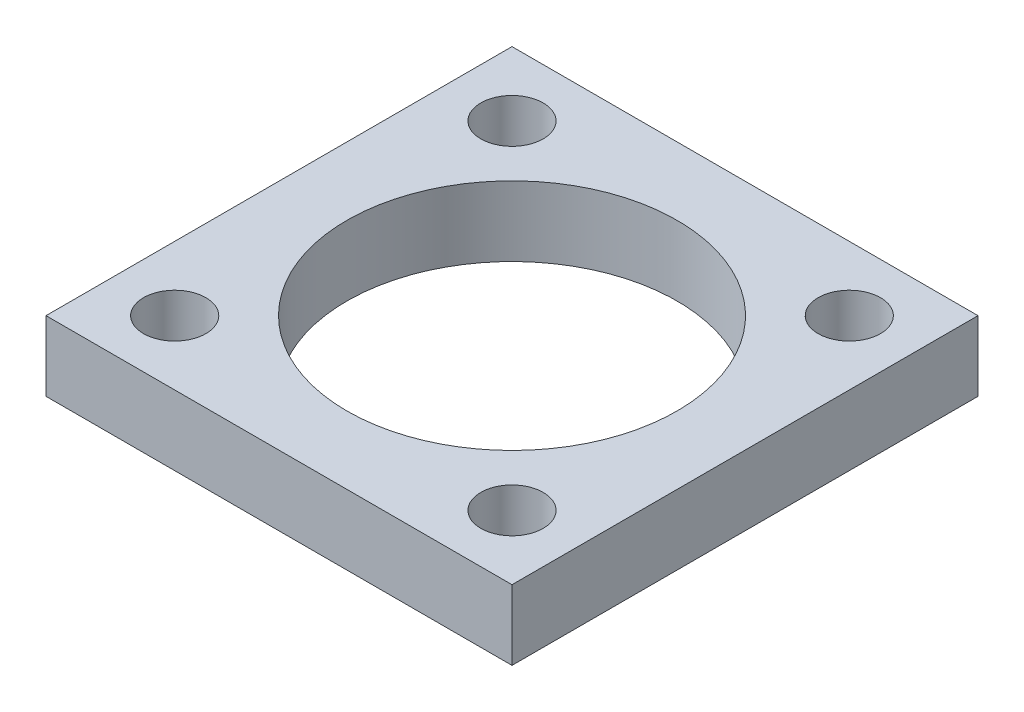
from build123d import *

# Parameters (mm, degrees)
SKETCH2_W            = 25.4
SKETCH2_H            = 25.4
BOSS_EXTRUDE1_DEPTH  = 3.81
SKETCH4_R            = 9
CUT_EXTRUDE1_DEPTH   = 4.81
M3_CLEARANCE_HOLE2_D = 3.4


with BuildPart() as part:
    # Sketch2 → Boss-Extrude1 (new body)
    with BuildSketch(Plane(origin=(0, 0, 0), x_dir=(1, 0, 0), z_dir=(0, 1, 0))):
        Rectangle(SKETCH2_W, SKETCH2_H)
    extrude(amount=BOSS_EXTRUDE1_DEPTH)

    # Sketch4 → Cut-Extrude1 (cut, through all)
    with BuildSketch(Plane(origin=(0, 3.81, 0), x_dir=(1, 0, 0), z_dir=(0, 1, 0))):
        Circle(SKETCH4_R)
    extrude(amount=-CUT_EXTRUDE1_DEPTH, mode=Mode.SUBTRACT)

    # M3 Clearance Hole2 (through all)
    with Locations(Plane(origin=(-9.192388155, 3.81, -9.192388155), x_dir=(0, 0, 1), z_dir=(0, 1, 0))):
        with Locations((0, 0), (18.38477631, 18.38477631), (0, 18.38477631), (18.38477631, 0)):
            Hole(M3_CLEARANCE_HOLE2_D / 2)


solid = part.part
